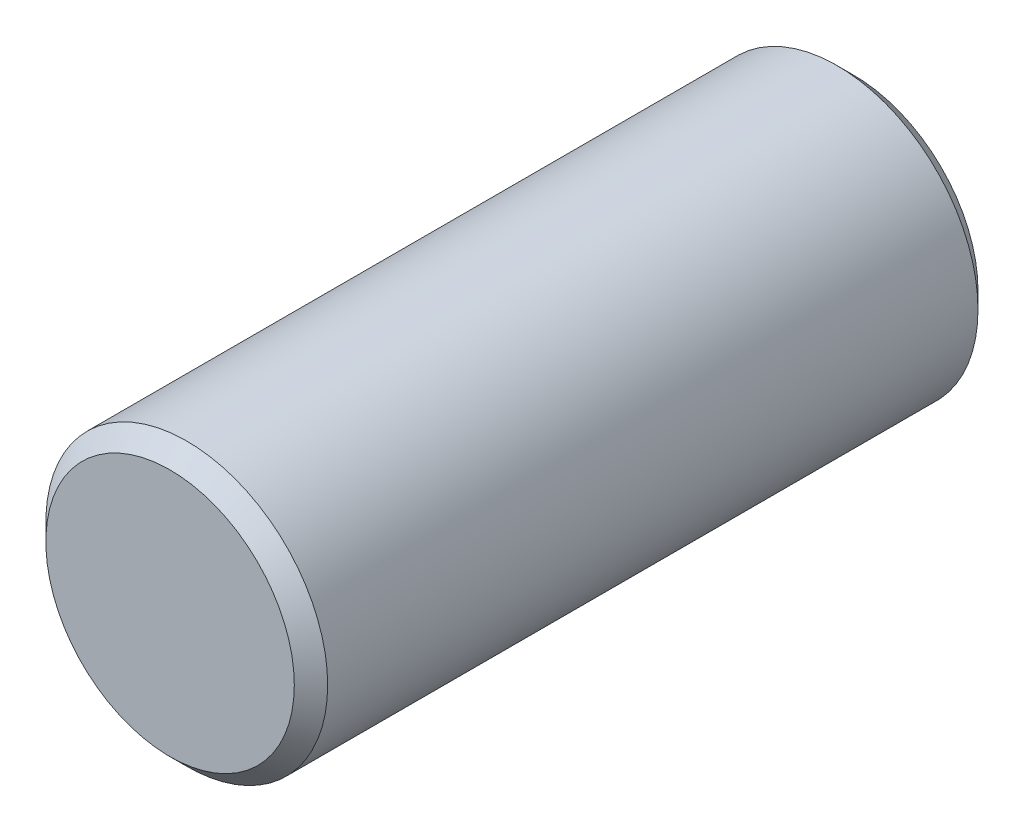
from build123d import *

# Parameters (mm, degrees)
SKETCH1_R           = 429.26
BOSS_EXTRUDE1_DEPTH = 1041.4
CHAMFER1_SIZE       = 50.8


with BuildPart() as part:
    # Sketch1 → Boss-Extrude1 (new body, symmetric)
    with BuildSketch(Plane.XY):
        Circle(SKETCH1_R)
    extrude(amount=BOSS_EXTRUDE1_DEPTH, both=True)

    # Chamfer1
    chamfer1_edges = [part.edges().sort_by_distance(p)[0] for p in [
        (-429.26, 0, -1041.4),
        (-429.26, 0, 1041.4),
    ]]
    chamfer(chamfer1_edges, length=CHAMFER1_SIZE)


solid = part.part
